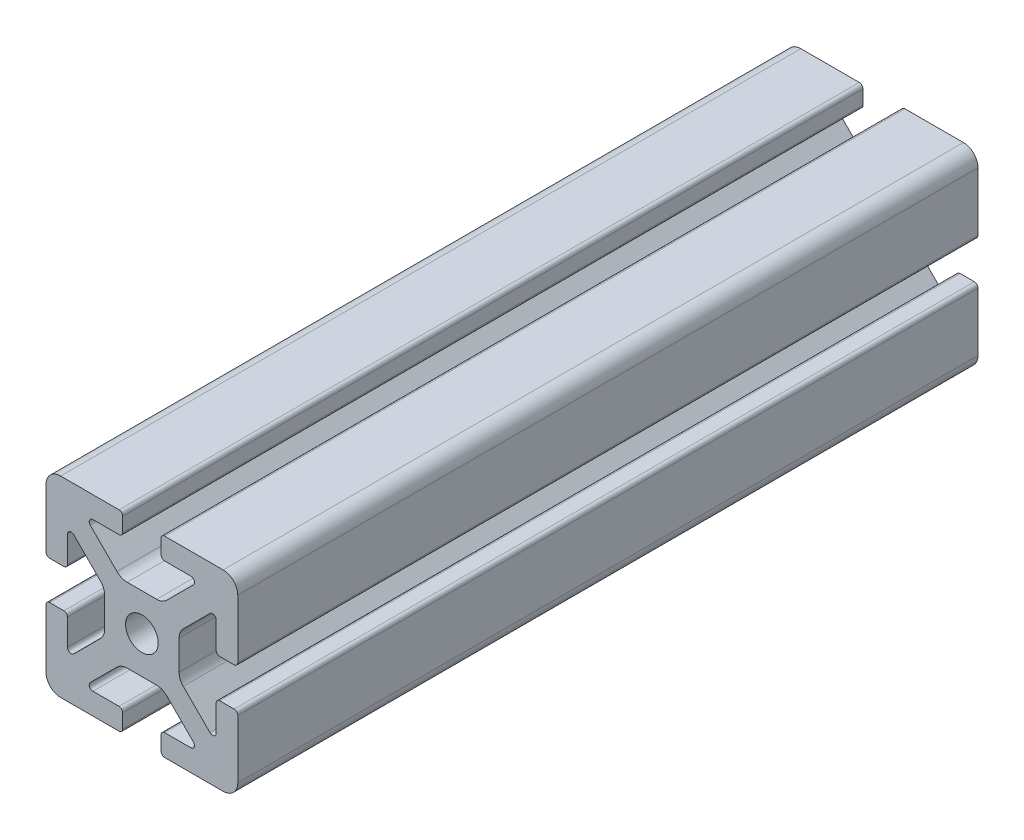
from build123d import *

# Parameters (mm, degrees)
SKETCH1_R               = 3.4036
BOSS_EXTRUDE1_DEPTH     = 380
SKETCH2_W               = 605.6
SKETCH2_H               = 40
CUT_EXTRUDE1_DEPTH      = 65
CUT_EXTRUDE1_DEPTH_BACK = 71


with BuildPart() as part:
    # Sketch1 → Boss-Extrude1 (new body, symmetric)
    with BuildSketch(Plane.XY):
        with BuildLine():
            Line((-20, 16.952), (-20, 4.7625))
            ThreePointArc((-20, 4.7625), (-19.776815367, 4.223684633), (-19.238, 4.0005))
            Line((-19.238, 4.0005), (-16.2662, 4.0005))
            ThreePointArc((-16.2662, 4.0005), (-15.727384633, 4.223684633), (-15.5042, 4.7625))
            Line((-15.5042, 4.7625), (-15.5042, 10.2235))
            ThreePointArc((-15.5042, 10.2235), (-15.033804775, 10.927496204), (-14.203384633, 10.762315367))
            Line((-14.203384633, 10.762315367), (-8.635059555, 5.19399029))
            ThreePointArc((-8.635059555, 5.19399029), (-7.985348265, 4.221628629), (-7.7572, 3.074649845))
            Line((-7.7572, 3.074649845), (-7.7572, -3.074649845))
            ThreePointArc((-7.7572, -3.074649845), (-7.985348265, -4.221628629), (-8.635059555, -5.19399029))
            Line((-8.635059555, -5.19399029), (-14.203384633, -10.762315367))
            ThreePointArc((-14.203384633, -10.762315367), (-15.033804775, -10.927496204), (-15.5042, -10.2235))
            Line((-15.5042, -10.2235), (-15.5042, -4.7625))
            ThreePointArc((-15.5042, -4.7625), (-15.727384633, -4.223684633), (-16.2662, -4.0005))
            Line((-16.2662, -4.0005), (-19.238, -4.0005))
            ThreePointArc((-19.238, -4.0005), (-19.776815367, -4.223684633), (-20, -4.7625))
            Line((-20, -4.7625), (-20, -16.952))
            ThreePointArc((-20, -16.952), (-19.107261469, -19.107261469), (-16.952, -20))
            Line((-16.952, -20), (-4.7625, -20))
            ThreePointArc((-4.7625, -20), (-4.223684633, -19.776815367), (-4.0005, -19.238))
            Line((-4.0005, -19.238), (-4.0005, -16.2662))
            ThreePointArc((-4.0005, -16.2662), (-4.223684633, -15.727384633), (-4.7625, -15.5042))
            Line((-4.7625, -15.5042), (-10.2235, -15.5042))
            ThreePointArc((-10.2235, -15.5042), (-10.927496204, -15.033804775), (-10.762315367, -14.203384633))
            Line((-10.762315367, -14.203384633), (-5.19399029, -8.635059555))
            ThreePointArc((-5.19399029, -8.635059555), (-4.221628629, -7.985348265), (-3.074649845, -7.7572))
            Line((-3.074649845, -7.7572), (3.074649845, -7.7572))
            ThreePointArc((3.074649845, -7.7572), (4.221628629, -7.985348265), (5.19399029, -8.635059555))
            Line((5.19399029, -8.635059555), (10.762315367, -14.203384633))
            ThreePointArc((10.762315367, -14.203384633), (10.927496204, -15.033804775), (10.2235, -15.5042))
            Line((10.2235, -15.5042), (4.7625, -15.5042))
            ThreePointArc((4.7625, -15.5042), (4.223684633, -15.727384633), (4.0005, -16.2662))
            Line((4.0005, -16.2662), (4.0005, -19.238))
            ThreePointArc((4.0005, -19.238), (4.223684633, -19.776815367), (4.7625, -20))
            Line((4.7625, -20), (16.952, -20))
            ThreePointArc((16.952, -20), (19.107261469, -19.107261469), (20, -16.952))
            Line((20, -16.952), (20, -4.7625))
            ThreePointArc((20, -4.7625), (19.776815367, -4.223684633), (19.238, -4.0005))
            Line((19.238, -4.0005), (16.2662, -4.0005))
            ThreePointArc((16.2662, -4.0005), (15.727384633, -4.223684633), (15.5042, -4.7625))
            Line((15.5042, -4.7625), (15.5042, -10.2235))
            ThreePointArc((15.5042, -10.2235), (15.033804775, -10.927496204), (14.203384633, -10.762315367))
            Line((14.203384633, -10.762315367), (8.635059555, -5.19399029))
            ThreePointArc((8.635059555, -5.19399029), (7.985348265, -4.221628629), (7.7572, -3.074649845))
            Line((7.7572, -3.074649845), (7.7572, 3.074649845))
            ThreePointArc((7.7572, 3.074649845), (7.985348265, 4.221628629), (8.635059555, 5.19399029))
            Line((8.635059555, 5.19399029), (14.203384633, 10.762315367))
            ThreePointArc((14.203384633, 10.762315367), (15.033804775, 10.927496204), (15.5042, 10.2235))
            Line((15.5042, 10.2235), (15.5042, 4.7625))
            ThreePointArc((15.5042, 4.7625), (15.727384633, 4.223684633), (16.2662, 4.0005))
            Line((16.2662, 4.0005), (19.238, 4.0005))
            ThreePointArc((19.238, 4.0005), (19.776815367, 4.223684633), (20, 4.7625))
            Line((20, 4.7625), (20, 16.952))
            ThreePointArc((20, 16.952), (19.107261469, 19.107261469), (16.952, 20))
            Line((16.952, 20), (4.7625, 20))
            ThreePointArc((4.7625, 20), (4.223684633, 19.776815367), (4.0005, 19.238))
            Line((4.0005, 19.238), (4.0005, 16.2662))
            ThreePointArc((4.0005, 16.2662), (4.223684633, 15.727384633), (4.7625, 15.5042))
            Line((4.7625, 15.5042), (10.2235, 15.5042))
            ThreePointArc((10.2235, 15.5042), (10.927496204, 15.033804775), (10.762315367, 14.203384633))
            Line((10.762315367, 14.203384633), (5.19399029, 8.635059555))
            ThreePointArc((5.19399029, 8.635059555), (4.221628629, 7.985348265), (3.074649845, 7.7572))
            Line((3.074649845, 7.7572), (-3.074649845, 7.7572))
            ThreePointArc((-3.074649845, 7.7572), (-4.221628629, 7.985348265), (-5.19399029, 8.635059555))
            Line((-5.19399029, 8.635059555), (-10.762315367, 14.203384633))
            ThreePointArc((-10.762315367, 14.203384633), (-10.927496204, 15.033804775), (-10.2235, 15.5042))
            Line((-10.2235, 15.5042), (-4.7625, 15.5042))
            ThreePointArc((-4.7625, 15.5042), (-4.223684633, 15.727384633), (-4.0005, 16.2662))
            Line((-4.0005, 16.2662), (-4.0005, 19.238))
            ThreePointArc((-4.0005, 19.238), (-4.223684633, 19.776815367), (-4.7625, 20))
            Line((-4.7625, 20), (-16.952, 20))
            ThreePointArc((-16.952, 20), (-19.107261469, 19.107261469), (-20, 16.952))
        make_face()
        Circle(SKETCH1_R, mode=Mode.SUBTRACT)
    extrude(amount=BOSS_EXTRUDE1_DEPTH, both=True)

    # Sketch2 → Cut-Extrude1 (cut, two sides)
    with BuildSketch(Plane(origin=(0, 0, 0), x_dir=(0, 0, -1), z_dir=(1, 0, 0))) as cut_extrude1_sk:
        with Locations((77.2, 0)):
            Rectangle(SKETCH2_W, SKETCH2_H)
    extrude(amount=CUT_EXTRUDE1_DEPTH, mode=Mode.SUBTRACT)
    extrude(cut_extrude1_sk.sketch, amount=-CUT_EXTRUDE1_DEPTH_BACK, mode=Mode.SUBTRACT)


solid = part.part
